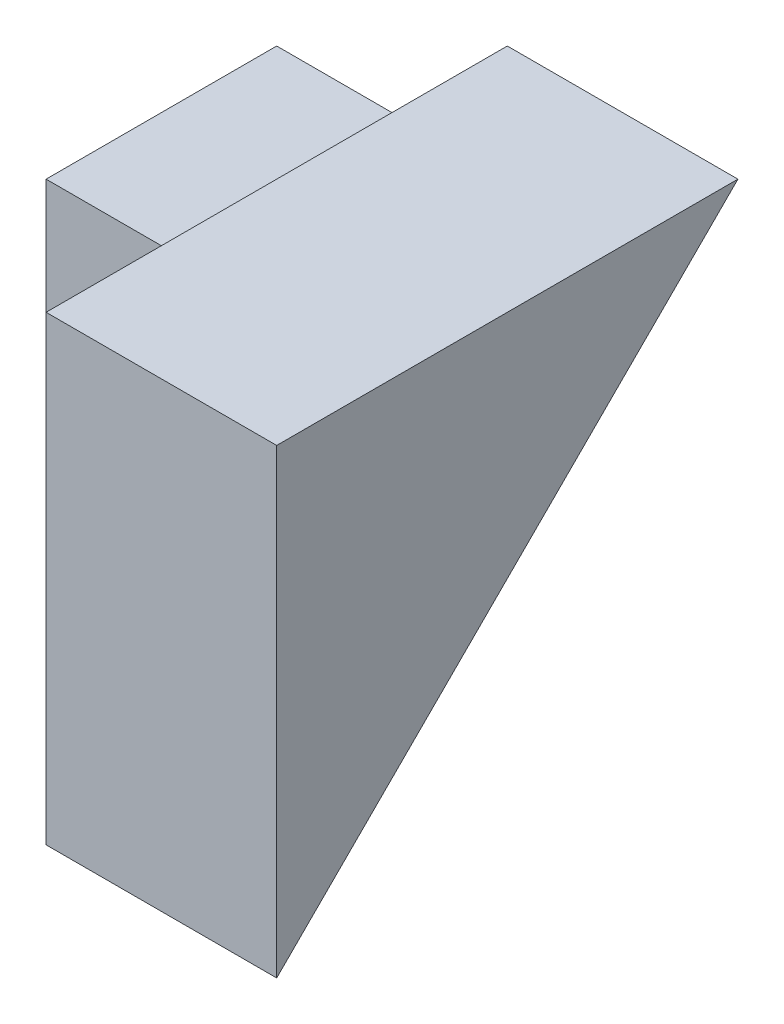
from build123d import *

# Parameters (mm, degrees)
SKETCH1_W           = 4
SKETCH1_H           = 4
BOSS_EXTRUDE1_DEPTH = 2
SKETCH2_W           = 2
SKETCH2_H           = 3
BOSS_EXTRUDE2_DEPTH = 2
CUT_EXTRUDE1_DEPTH  = 2


with BuildPart() as part:
    # Sketch1 → Boss-Extrude1 (new body)
    with BuildSketch(Plane(origin=(0, 0, 0), x_dir=(0, 0, -1), z_dir=(1, 0, 0))):
        with Locations((2, 2)):
            Rectangle(SKETCH1_W, SKETCH1_H)
    extrude(amount=BOSS_EXTRUDE1_DEPTH)

    # Sketch2 → Boss-Extrude2 (add)
    with BuildSketch(Plane.ZY):
        with Locations((-3, 1.5)):
            Rectangle(SKETCH2_W, SKETCH2_H)
    extrude(amount=BOSS_EXTRUDE2_DEPTH)

    # Sketch3 → Cut-Extrude1 (cut)
    with BuildSketch(Plane(origin=(2, 0, 0), x_dir=(0, 0, -1), z_dir=(1, 0, 0))):
        Polygon((4, 4), (0, 0), (4, 0), align=None)
    extrude(amount=-CUT_EXTRUDE1_DEPTH, mode=Mode.SUBTRACT)


solid = part.part
